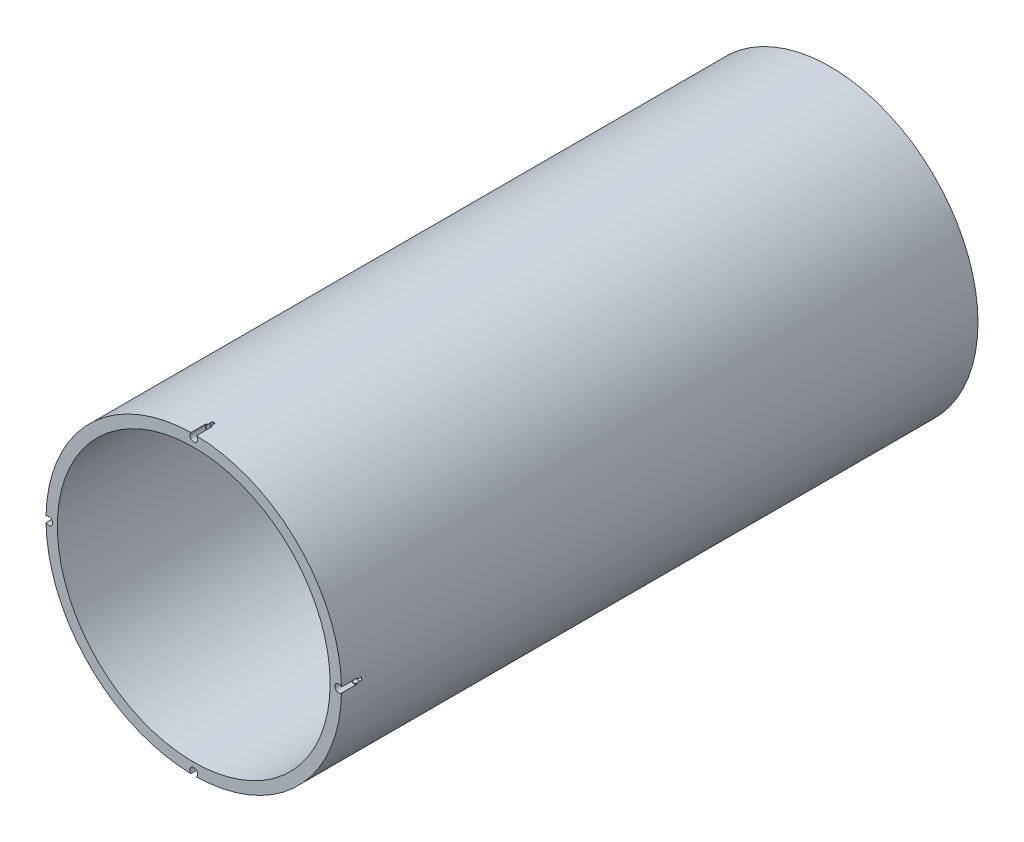
from build123d import *

# Parameters (mm, degrees)
SKETCH1_R                       = 41.275
SKETCH1_R_2                     = 38.1
BOSS_EXTRUDE1_DEPTH             = 177.8
F_2_56_TAPPED_HOLE1_D           = 1.778
F_2_56_TAPPED_HOLE1_DEPTH       = 5.588
F_2_56_TAPPED_HOLE1_CBORE_D     = 2.1844
F_2_56_TAPPED_HOLE1_CBORE_DEPTH = 4.318
F_2_56_TAPPED_HOLE1_TIP         = 0.53416509


with BuildPart() as part:
    # Sketch1 → Boss-Extrude1 (new body)
    with BuildSketch(Plane.XY):
        Circle(SKETCH1_R)
        Circle(SKETCH1_R_2, mode=Mode.SUBTRACT)
    extrude(amount=BOSS_EXTRUDE1_DEPTH)

    # #2-56 Tapped Hole1
    with Locations(Plane.XY.offset(177.8)):
        with Locations((0, 40.48125), (40.48125, 0), (0, -40.48125), (-40.48125, 0)):
            CounterBoreHole(F_2_56_TAPPED_HOLE1_D / 2, F_2_56_TAPPED_HOLE1_CBORE_D / 2, F_2_56_TAPPED_HOLE1_CBORE_DEPTH, depth=F_2_56_TAPPED_HOLE1_DEPTH)
            with Locations((0, 0, -(F_2_56_TAPPED_HOLE1_DEPTH + F_2_56_TAPPED_HOLE1_TIP / 2))):  # 118° drill point
                Cone(0, F_2_56_TAPPED_HOLE1_D / 2, F_2_56_TAPPED_HOLE1_TIP, mode=Mode.SUBTRACT)


solid = part.part
